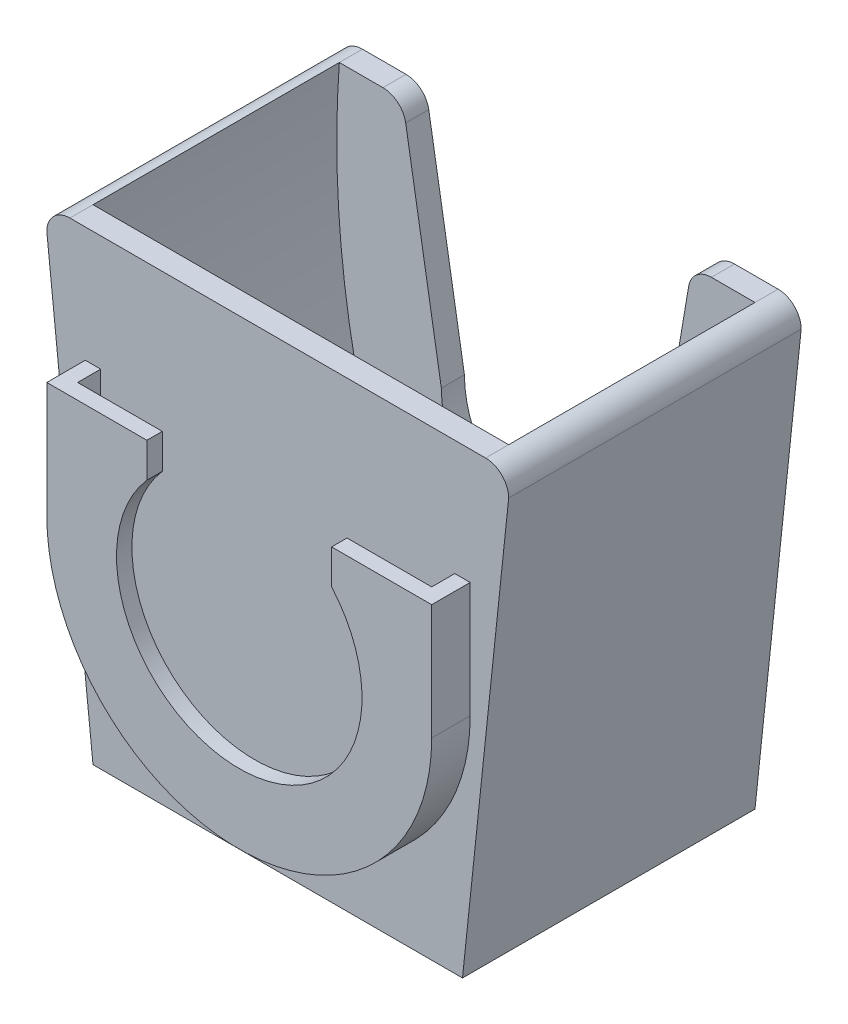
from build123d import *

# Parameters (mm, degrees)
SALIENTE_EXTRUIR5_DEPTH  = 19
CORTAR_EXTRUIR8_DEPTH    = 16
SALIENTE_EXTRUIR8_DEPTH  = 3
REVOLUCI_N7_ANGLE        = 180
SALIENTE_EXTRUIR10_DEPTH = 15
CORTAR_EXTRUIR7_START    = 22
CORTAR_EXTRUIR7_DEPTH    = 2


with BuildPart() as part:
    # Croquis1 → Saliente-Extruir5 (new body, symmetric)
    with BuildSketch(Plane.XY):
        with BuildLine():
            Line((-27, 30), (-21.336320434, 30))
            ThreePointArc((-21.336320434, 30), (-19.399015955, 29.290600654), (-18.377926496, 27.497900903))
            Line((-18.377926496, 27.497900903), (-13.75, 0))
            ThreePointArc((-13.75, 0), (0, -13.75), (13.75, 0))
            Line((13.75, 0), (18.377926496, 27.497900903))
            ThreePointArc((18.377926496, 27.497900903), (19.399015955, 29.290600654), (21.336320434, 30))
            Line((21.336320434, 30), (27, 30))
            ThreePointArc((27, 30), (29.121320344, 29.121320344), (30, 27))
            Line((30, 27), (24, -30))
            Line((24, -30), (-24, -30))
            Line((-24, -30), (-30, 27))
            ThreePointArc((-30, 27), (-29.121320344, 29.121320344), (-27, 30))
        make_face()
    extrude(amount=SALIENTE_EXTRUIR5_DEPTH, both=True)

    # Croquis22 → Cortar-Extruir8 (cut, symmetric)
    with BuildSketch(Plane.XY):
        with BuildLine():
            Line((16, -30), (-16, -30))
            ThreePointArc((-16, -30), (-25.355108055, -0.70676981), (-27, 30))
            Line((-27, 30), (-18, 30))
            Line((-18, 30), (-13.75, 0))
            ThreePointArc((-13.75, 0), (0, -13.75), (13.75, 0))
            Line((13.75, 0), (18, 30))
            Line((18, 30), (27, 30))
            ThreePointArc((27, 30), (25.355108055, -0.70676981), (16, -30))
        make_face()
    extrude(amount=CORTAR_EXTRUIR8_DEPTH, both=True, mode=Mode.SUBTRACT)

    # Croquis8 → Saliente-Extruir8 (add)
    with BuildSketch(Plane.XY.offset(19)):
        Polygon((-21.336320434, 30), (21.336320434, 30), (21.336320434, -14), (0, -13.75), (-21.336320434, -14), align=None)
    extrude(amount=-SALIENTE_EXTRUIR8_DEPTH)

    # Croquis16 → Revolución7 (revolve)
    with BuildSketch(Plane(origin=(0, 0, 0), x_dir=(1, 0, 0), z_dir=(0, 1, 0))):
        Polygon((0, -22), (0, -24), (-25, -24), (-25, -19), (-23, -19), (-23, -22), align=None)
    revolve(axis=Axis((0, 0, 22), (0, 0, 1)), revolution_arc=REVOLUCI_N7_ANGLE)

    # Croquis18 → Saliente-Extruir10 (add)
    with BuildSketch(Plane(origin=(0, 0, 0), x_dir=(1, 0, 0), z_dir=(0, 1, 0))):
        Polygon((-25, -24), (25, -24), (25, -19), (23, -19), (23, -22), (-23, -22), (-23, -19), (-25, -19), align=None)
    extrude(amount=SALIENTE_EXTRUIR10_DEPTH)

    # Croquis19 → Cortar-Extruir7 (cut)
    with BuildSketch(Plane.XY.offset(CORTAR_EXTRUIR7_START)):
        with BuildLine():
            Line((-12, 10.5), (-12, 15))
            Line((-12, 15), (12, 15))
            Line((12, 15), (12, 10.5))
            ThreePointArc((12, 10.5), (0, -15.945218719), (-12, 10.5))
        make_face()
    extrude(amount=CORTAR_EXTRUIR7_DEPTH, mode=Mode.SUBTRACT)


solid = part.part
